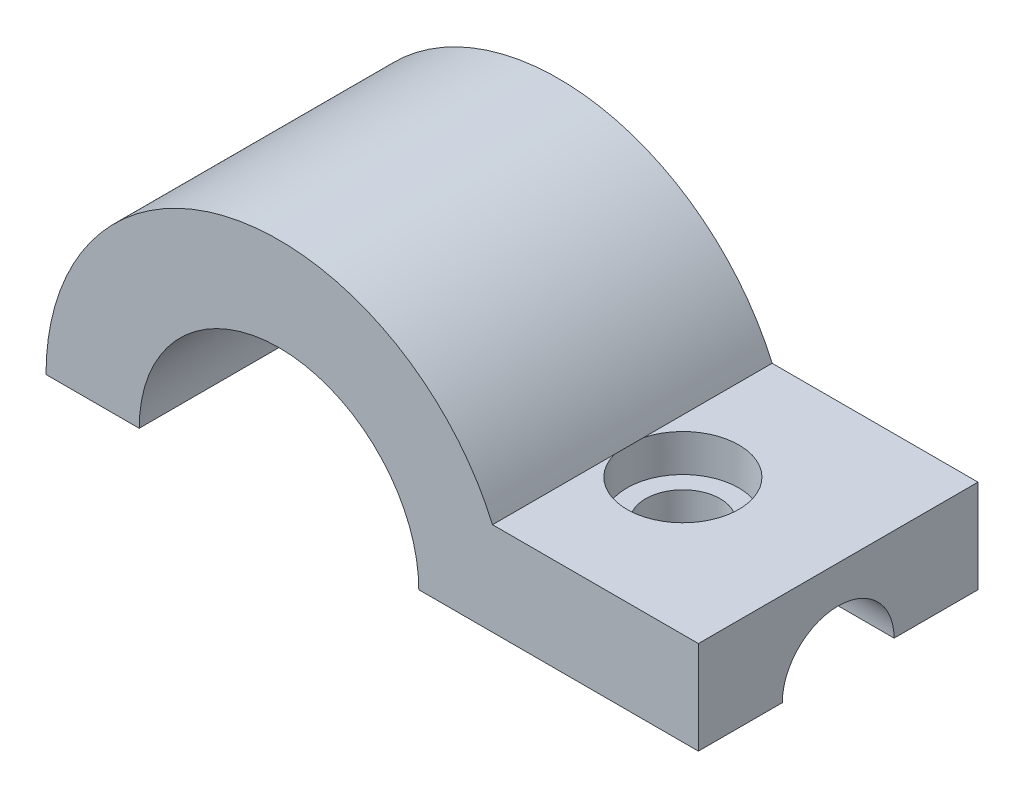
from build123d import *

# Parameters (mm, degrees)
EXTRUDE_1_DEPTH     = 1.5
SKETCH_3_R          = 0.2
CUT_EXTRUDE_1_DEPTH = 1.5
SKETCH_4_R          = 0.3
CUT_EXTRUDE_2_DEPTH = 0.5
SKETCH_5_R          = 0.3
CUT_EXTRUDE_3_DEPTH = 0.2


with BuildPart() as part:
    # 草图2 → 凸台-拉伸1 (new body)
    with BuildSketch(Plane.XY):
        with BuildLine():
            Line((-11.25, 0), (-10.75, 0))
            ThreePointArc((-10.75, 0), (-10, 0.75), (-9.25, 0))
            Line((-9.25, 0), (-7.75, 0))
            Line((-7.75, 0), (-7.75, 0.5))
            Line((-7.75, 0.5), (-8.854356076, 0.5))
            ThreePointArc((-8.854356076, 0.5), (-10.255387055, 1.223632891), (-11.25, 0))
        make_face()
    extrude(amount=-EXTRUDE_1_DEPTH)

    # 草图3 → 切除-拉伸1 (cut)
    with BuildSketch(Plane(origin=(0, 0.5, 0), x_dir=(1, 0, 0), z_dir=(0, 1, 0))):
        with Locations((-8.564809318, 0.731541815)):
            Circle(SKETCH_3_R)
    extrude(amount=-CUT_EXTRUDE_1_DEPTH, mode=Mode.SUBTRACT)

    # 草图4 → 切除-拉伸2 (cut)
    with BuildSketch(Plane(origin=(-7.75, 0, 0), x_dir=(0, 0, -1), z_dir=(1, 0, 0))):
        with Locations((0.75, 0)):
            Circle(SKETCH_4_R)
    extrude(amount=-CUT_EXTRUDE_2_DEPTH, mode=Mode.SUBTRACT)

    # 草图5 → 切除-拉伸3 (cut)
    with BuildSketch(Plane(origin=(0, 0.5, 0), x_dir=(1, 0, 0), z_dir=(0, 1, 0))):
        with Locations((-8.564809318, 0.731541815)):
            Circle(SKETCH_5_R)
    extrude(amount=-CUT_EXTRUDE_3_DEPTH, mode=Mode.SUBTRACT)


solid = part.part
